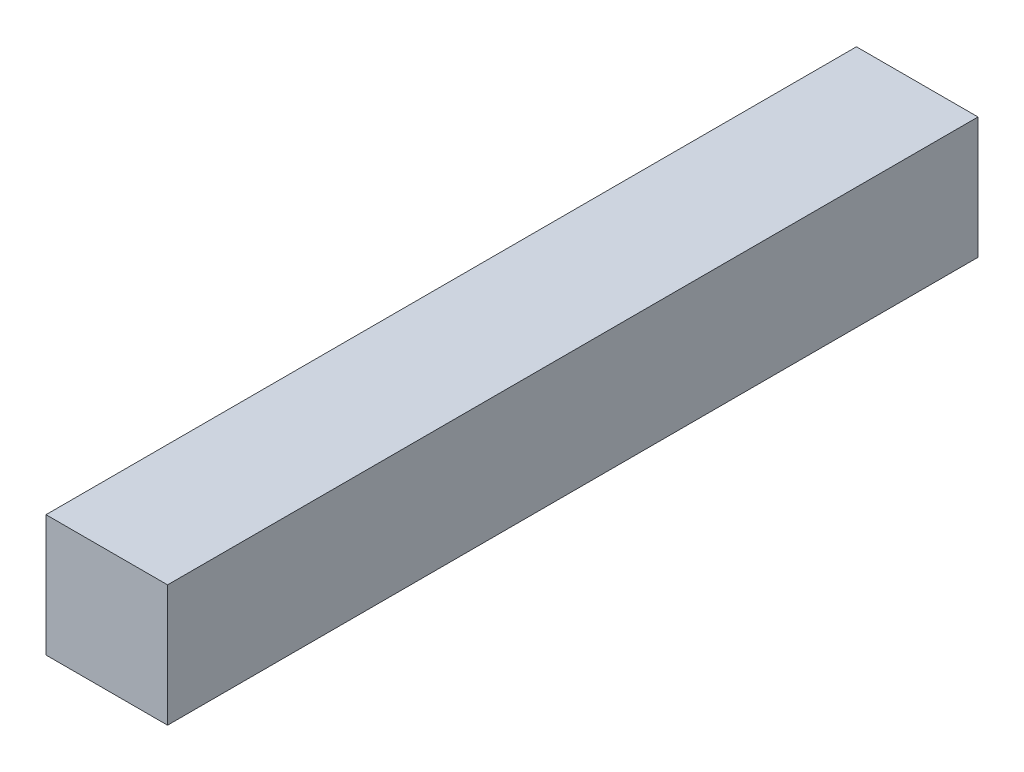
from build123d import *

# Parameters (mm, degrees)
SKETCH1_W           = 45
SKETCH1_H           = 45
BOSS_EXTRUDE1_DEPTH = 300


with BuildPart() as part:
    # Sketch1 → Boss-Extrude1 (new body)
    with BuildSketch(Plane.XY):
        with Locations((22.5, 22.5)):
            Rectangle(SKETCH1_W, SKETCH1_H)
    extrude(amount=BOSS_EXTRUDE1_DEPTH)


solid = part.part
